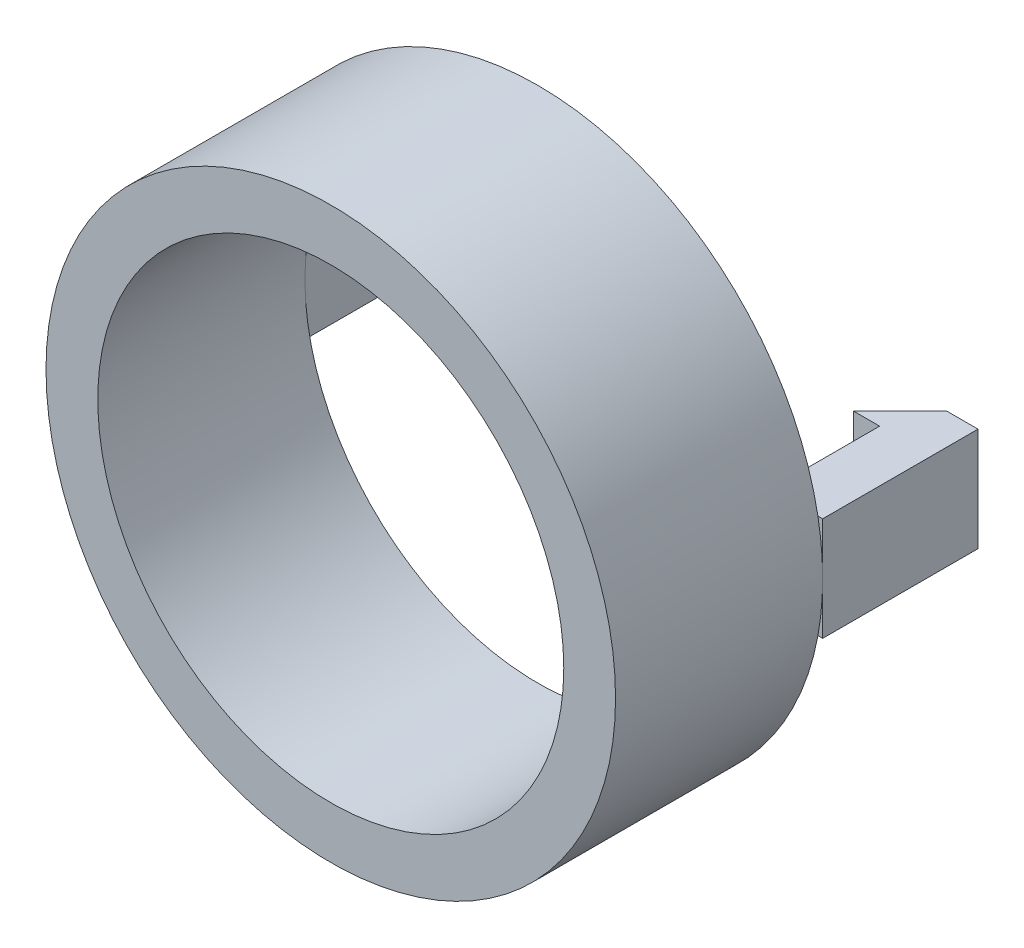
from build123d import *

# Parameters (mm, degrees)
SKETCH1_R           = 11
SKETCH1_R_2         = 9
BOSS_EXTRUDE1_DEPTH = 8
BOSS_EXTRUDE2_DEPTH = 2


with BuildPart() as part:
    # Sketch1 → Boss-Extrude1 (new body)
    with BuildSketch(Plane.XY):
        Circle(SKETCH1_R)
        Circle(SKETCH1_R_2, mode=Mode.SUBTRACT)
    extrude(amount=BOSS_EXTRUDE1_DEPTH)

    # Sketch2 → Boss-Extrude2 (add, symmetric)
    with BuildSketch(Plane(origin=(0, 0, 0), x_dir=(1, 0, 0), z_dir=(0, 1, 0))):
        Polygon((-11, 0), (-11, 6), (-9.8, 6), (-8, 4.2), (-9, 4.2), (-9, 0), align=None)
        Polygon((9, 0), (11, 0), (11, 6), (9.8, 6), (8, 4.2), (9, 4.2), align=None)
    extrude(amount=BOSS_EXTRUDE2_DEPTH, both=True)


solid = part.part
